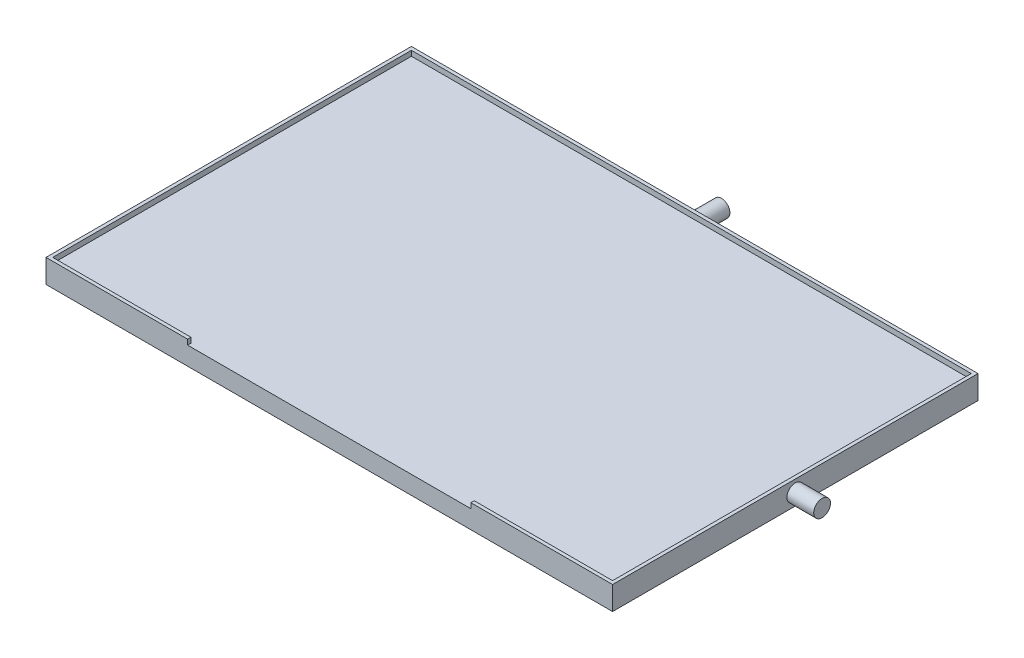
from build123d import *

# Parameters (mm, degrees)
SKETCH1_W               = 169
SKETCH1_H               = 7
BOSS_EXTRUDE1_DEPTH     = 109
SKETCH3_W               = 165
SKETCH3_H               = 105
CUT_EXTRUDE2_DEPTH      = 1.5
SKETCH4_W               = 84.5
SKETCH4_H               = 1.55
CUT_EXTRUDE3_DEPTH      = 2
SKETCH5_R               = 2.5
BOSS_EXTRUDE2_DEPTH     = 8
SKETCH6_R               = 2.5
BOSS_EXTRUDE3_DEPTH     = 8
SKETCH8_W               = 10
SKETCH8_H               = 15
BOSS_EXTRUDE4_DEPTH     = 10
SKETCH9_R               = 2.55
CUT_EXTRUDE4_DEPTH      = 35.1
CUT_EXTRUDE4_DEPTH_BACK = 5.1
SKETCH10_W              = 167
SKETCH10_H              = 107
CUT_EXTRUDE5_DEPTH      = 1.55


with BuildPart() as part:
    # Sketch1 → Boss-Extrude1 (new body)
    with BuildSketch(Plane.XY):
        with Locations((84.5, 3.5)):
            Rectangle(SKETCH1_W, SKETCH1_H)
    extrude(amount=-BOSS_EXTRUDE1_DEPTH)

    # Sketch3 → Cut-Extrude2 (cut)
    with BuildSketch(Plane(origin=(0, 7, 0), x_dir=(1, 0, 0), z_dir=(0, 1, 0))):
        with Locations((84.5, 54.5)):
            Rectangle(SKETCH3_W, SKETCH3_H)
    extrude(amount=-CUT_EXTRUDE2_DEPTH, mode=Mode.SUBTRACT)

    # Sketch4 → Cut-Extrude3 (cut)
    with BuildSketch(Plane.XY):
        with Locations((84.5, 6.225)):
            Rectangle(SKETCH4_W, SKETCH4_H)
    extrude(amount=-CUT_EXTRUDE3_DEPTH, mode=Mode.SUBTRACT)

    # Sketch5 → Boss-Extrude2 (add)
    with BuildSketch(Plane(origin=(169, 0, 0), x_dir=(0, 0, -1), z_dir=(1, 0, 0))):
        with Locations((54.5, 3.5)):
            Circle(SKETCH5_R)
    extrude(amount=BOSS_EXTRUDE2_DEPTH)

    # Sketch6 → Boss-Extrude3 (add)
    with BuildSketch(Plane(origin=(0, 0, -109), x_dir=(-1, 0, 0), z_dir=(0, 0, -1))):
        with Locations((-84.5, 3.5)):
            Circle(SKETCH6_R)
    extrude(amount=BOSS_EXTRUDE3_DEPTH)

    # Sketch8 → Boss-Extrude4 (add)
    with BuildSketch(Plane.XZ):
        with Locations((104.5, -54.5)):
            Rectangle(SKETCH8_W, SKETCH8_H)
        with Locations((64.5, -54.5)):
            Rectangle(SKETCH8_W, SKETCH8_H)
    extrude(amount=BOSS_EXTRUDE4_DEPTH)

    # Sketch9 → Cut-Extrude4 (cut, two sides)
    with BuildSketch(Plane(origin=(69.5, 0, 0), x_dir=(0, 0, -1), z_dir=(1, 0, 0))) as cut_extrude4_sk:
        with Locations((54.5, -10)):
            Circle(SKETCH9_R)
    extrude(amount=CUT_EXTRUDE4_DEPTH, mode=Mode.SUBTRACT)
    extrude(cut_extrude4_sk.sketch, amount=-CUT_EXTRUDE4_DEPTH_BACK, mode=Mode.SUBTRACT)

    # Sketch10 → Cut-Extrude5 (cut)
    with BuildSketch(Plane(origin=(0, 7, 0), x_dir=(1, 0, 0), z_dir=(0, 1, 0))):
        with Locations((84.5, 54.5)):
            Rectangle(SKETCH10_W, SKETCH10_H)
    extrude(amount=-CUT_EXTRUDE5_DEPTH, mode=Mode.SUBTRACT)


solid = part.part
